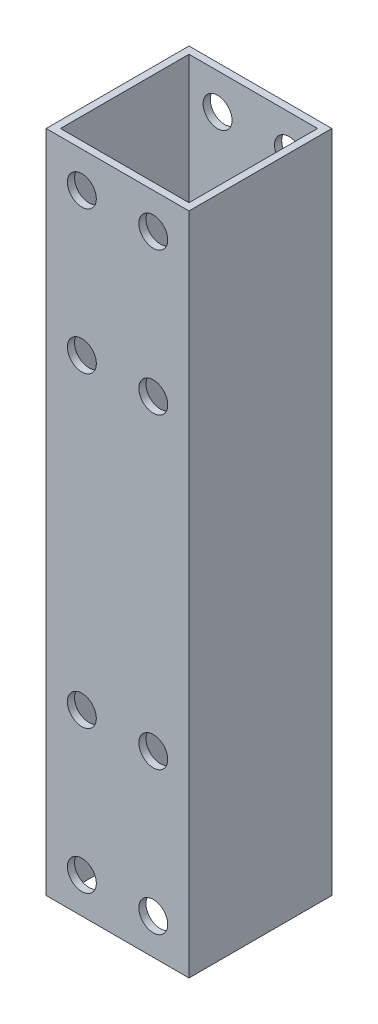
from build123d import *

# Parameters (mm, degrees)
SKETCH_1_W          = 20
SKETCH_1_H          = 20
SKETCH_1_W_2        = 18
SKETCH_1_H_2        = 18
EXTRUDE_1_DEPTH     = 93
SKETCH_2_R          = 2.025
CUT_EXTRUDE_1_DEPTH = 21


with BuildPart() as part:
    # 草图1 → 凸台-拉伸1 (new body)
    with BuildSketch(Plane(origin=(0, 0, 0), x_dir=(1, 0, 0), z_dir=(0, 1, 0))):
        Rectangle(SKETCH_1_W, SKETCH_1_H)
        Rectangle(SKETCH_1_W_2, SKETCH_1_H_2, mode=Mode.SUBTRACT)
    extrude(amount=EXTRUDE_1_DEPTH)

    # 草图2 → 切除-拉伸1 (cut, through all)
    with BuildSketch(Plane.XY.offset(10)):
        with Locations((-5, 5)):
            Circle(SKETCH_2_R)
        with Locations((-5, 25)):
            Circle(SKETCH_2_R)
        with Locations((5, 25)):
            Circle(SKETCH_2_R)
        with Locations((5, 5)):
            Circle(SKETCH_2_R)
        with Locations((5, 88)):
            Circle(SKETCH_2_R)
        with Locations((-5, 88)):
            Circle(SKETCH_2_R)
        with Locations((-5, 68)):
            Circle(SKETCH_2_R)
        with Locations((5, 68)):
            Circle(SKETCH_2_R)
    extrude(amount=-CUT_EXTRUDE_1_DEPTH, mode=Mode.SUBTRACT)


solid = part.part
